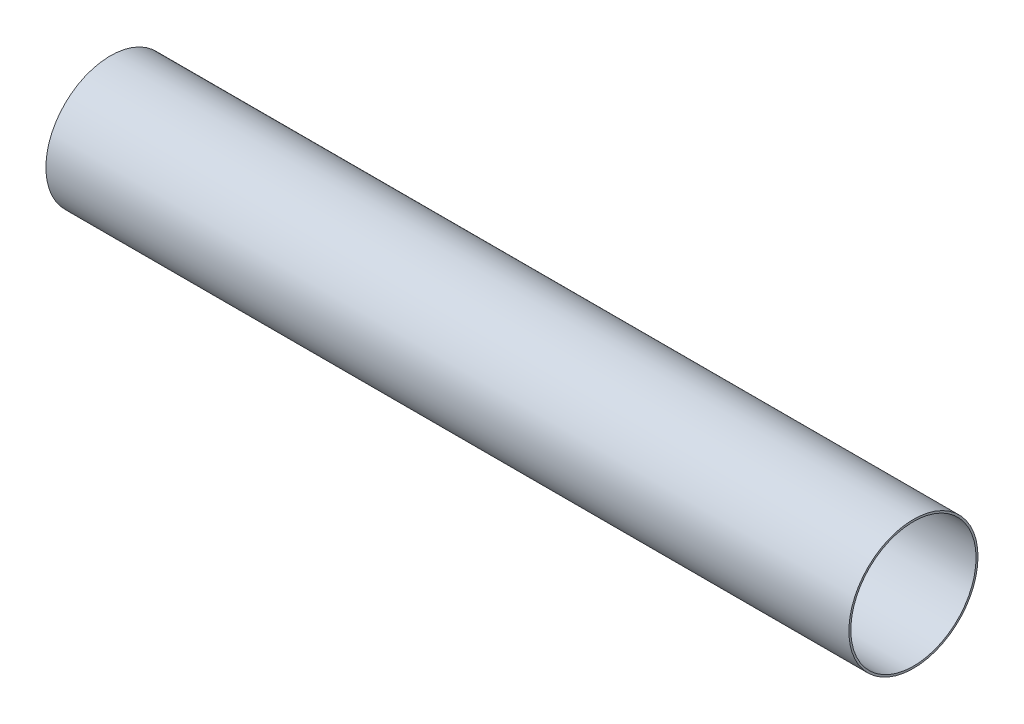
from build123d import *

# Parameters (mm, degrees)
SKETCH1_R           = 51.054
SKETCH1_R_2         = 49.53
BOSS_EXTRUDE1_DEPTH = 635


with BuildPart() as part:
    # Sketch1 → Boss-Extrude1 (new body)
    with BuildSketch(Plane.YZ):
        Circle(SKETCH1_R)
        Circle(SKETCH1_R_2, mode=Mode.SUBTRACT)
    extrude(amount=BOSS_EXTRUDE1_DEPTH)


solid = part.part
